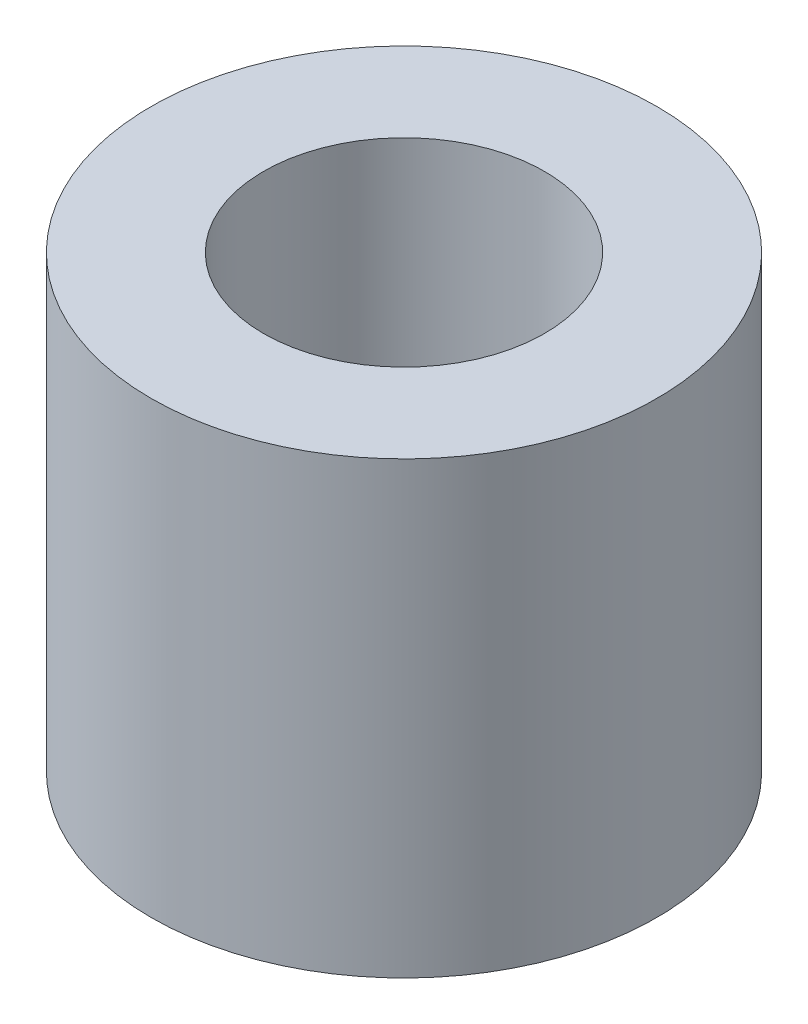
from build123d import *

# Parameters (mm, degrees)
SKETCH1_R           = 4.5
SKETCH1_R_2         = 2.5
BOSS_EXTRUDE1_DEPTH = 8


with BuildPart() as part:
    # Sketch1 → Boss-Extrude1 (new body)
    with BuildSketch(Plane(origin=(0, 0, 0), x_dir=(1, 0, 0), z_dir=(0, 1, 0))):
        Circle(SKETCH1_R)
        Circle(SKETCH1_R_2, mode=Mode.SUBTRACT)
    extrude(amount=BOSS_EXTRUDE1_DEPTH)


solid = part.part
